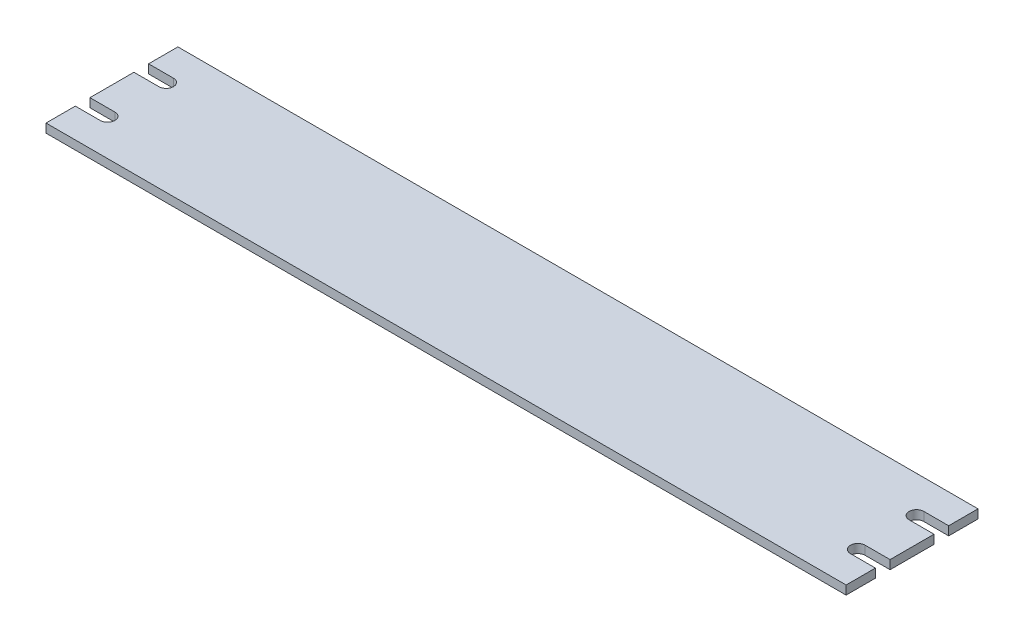
from build123d import *

# Parameters (mm, degrees)
SKETCH2_W           = 273
SKETCH2_H           = 45
BOSS_EXTRUDE1_DEPTH = 3
CUT_EXTRUDE1_DEPTH  = 4


with BuildPart() as part:
    # Sketch2 → Boss-Extrude1 (new body)
    with BuildSketch(Plane(origin=(0, 0, 0), x_dir=(1, 0, 0), z_dir=(0, 1, 0))):
        Rectangle(SKETCH2_W, SKETCH2_H)
    extrude(amount=BOSS_EXTRUDE1_DEPTH)

    # Sketch3 → Cut-Extrude1 (cut, through all)
    with BuildSketch(Plane(origin=(0, 3, 0), x_dir=(1, 0, 0), z_dir=(0, 1, 0))):
        with BuildLine():
            Line((-136.5, 12.5), (-128, 12.5))
            ThreePointArc((-128, 12.5), (-125.5, 10), (-128, 7.5))
            Line((-128, 7.5), (-136.5, 7.5))
            ThreePointArc((-136.5, 7.5), (-139, 10), (-136.5, 12.5))
        make_face()
        with BuildLine():
            Line((-136.5, -12.5), (-128, -12.5))
            ThreePointArc((-128, -12.5), (-125.5, -10), (-128, -7.5))
            Line((-128, -7.5), (-136.5, -7.5))
            ThreePointArc((-136.5, -7.5), (-139, -10), (-136.5, -12.5))
        make_face()
        with BuildLine():
            Line((136.5, 12.5), (128, 12.5))
            ThreePointArc((128, 12.5), (125.5, 10), (128, 7.5))
            Line((128, 7.5), (136.5, 7.5))
            ThreePointArc((136.5, 7.5), (139, 10), (136.5, 12.5))
        make_face()
        with BuildLine():
            Line((136.5, -12.5), (128, -12.5))
            ThreePointArc((128, -12.5), (125.5, -10), (128, -7.5))
            Line((128, -7.5), (136.5, -7.5))
            ThreePointArc((136.5, -7.5), (139, -10), (136.5, -12.5))
        make_face()
    extrude(amount=-CUT_EXTRUDE1_DEPTH, mode=Mode.SUBTRACT)


solid = part.part
